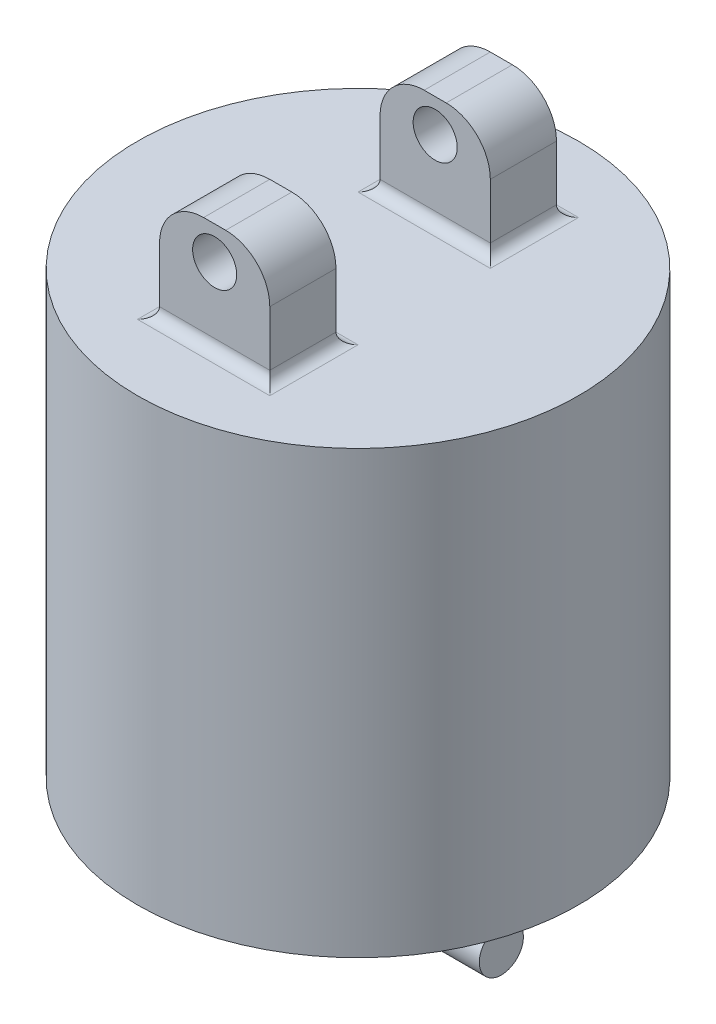
from build123d import *

# Parameters (mm, degrees)
SKETCH1_R                = 50
BOSS_EXTRUDE1_DEPTH      = 100
SKETCH6_W                = 25
SKETCH6_H                = 15
BOSS_EXTRUDE3_DEPTH      = 25
FILLET3_R                = 2.5
FILLET4_R                = 10
SKETCH7_R                = 5
CUT_EXTRUDE2_DEPTH       = 25
CIRPATTERN1_COUNT        = 2
FILLET3_OF_CIRPATTERN1_R = 2.5
FILLET4_OF_CIRPATTERN1_R = 10
SKETCH9_W                = 25
SKETCH9_H                = 25
BOSS_EXTRUDE4_DEPTH      = 15
BOSS_EXTRUDE4_DEPTH_BACK = 15
FILLET5_R                = 2.5
FILLET6_R                = 10
SKETCH10_R               = 5
BOSS_EXTRUDE5_DEPTH      = 32.5
BOSS_EXTRUDE5_DEPTH_BACK = 32.5


with BuildPart() as part:
    # Sketch1 → Boss-Extrude1 (new body)
    with BuildSketch(Plane(origin=(0, 0, 0), x_dir=(1, 0, 0), z_dir=(0, 1, 0))):
        Circle(SKETCH1_R)
    extrude(amount=BOSS_EXTRUDE1_DEPTH)

    # Sketch6 → Boss-Extrude3 (add)
    with BuildSketch(Plane(origin=(0, 100, 0), x_dir=(1, 0, 0), z_dir=(0, 1, 0))):
        with Locations((0, -25)):
            Rectangle(SKETCH6_W, SKETCH6_H)
    boss_extrude3 = extrude(amount=BOSS_EXTRUDE3_DEPTH)

    # Fillet3
    fillet3_edges = [part.edges().sort_by_distance(p)[0] for p in [
        (12.5, 100, 25),
        (0, 100, 17.5),
        (-12.5, 100, 25),
        (0, 100, 32.5),
    ]]
    fillet(fillet3_edges, radius=FILLET3_R)

    # Fillet4
    fillet4_edges = [part.edges().sort_by_distance(p)[0] for p in [
        (12.5, 125, 25),
        (-12.5, 125, 25),
    ]]
    fillet(fillet4_edges, radius=FILLET4_R)

    # Sketch7 → Cut-Extrude2 (cut)
    with BuildSketch(Plane.XY.offset(32.5)):
        with Locations((0, 117.5)):
            Circle(SKETCH7_R)
    cut_extrude2 = extrude(amount=-CUT_EXTRUDE2_DEPTH, mode=Mode.SUBTRACT)

    # CirPattern1: Boss-Extrude3, Cut-Extrude2 ×2 about axis
    cirpattern1_axis = Axis((0, 0, 0), (0, 1, 0))
    for i in range(1, CIRPATTERN1_COUNT):
        add(boss_extrude3.rotate(cirpattern1_axis, i * 360 / CIRPATTERN1_COUNT))
        add(cut_extrude2.rotate(cirpattern1_axis, i * 360 / CIRPATTERN1_COUNT), mode=Mode.SUBTRACT)

    # Fillet3 of CirPattern1
    fillet3_of_cirpattern1_edges = [part.edges().sort_by_distance(p)[0] for p in [
        (-12.5, 100, -25),
        (0, 100, -17.5),
        (12.5, 100, -25),
        (0, 100, -32.5),
    ]]
    fillet(fillet3_of_cirpattern1_edges, radius=FILLET3_OF_CIRPATTERN1_R)

    # Fillet4 of CirPattern1
    fillet4_of_cirpattern1_edges = [part.edges().sort_by_distance(p)[0] for p in [
        (-12.5, 125, -25),
        (12.5, 125, -25),
    ]]
    fillet(fillet4_of_cirpattern1_edges, radius=FILLET4_OF_CIRPATTERN1_R)

    # Sketch9 → Boss-Extrude4 (add, two sides)
    with BuildSketch(Plane(origin=(0, 0, 0), x_dir=(0, 0, -1), z_dir=(1, 0, 0))) as boss_extrude4_sk:
        with Locations((0, -12.5)):
            Rectangle(SKETCH9_W, SKETCH9_H)
    extrude(amount=BOSS_EXTRUDE4_DEPTH)
    extrude(boss_extrude4_sk.sketch, amount=-BOSS_EXTRUDE4_DEPTH_BACK)

    # Fillet5
    fillet5_edges = [part.edges().sort_by_distance(p)[0] for p in [
        (0, 0, 12.5),
        (-15, 0, 0),
        (0, 0, -12.5),
        (15, 0, 0),
    ]]
    fillet(fillet5_edges, radius=FILLET5_R)

    # Fillet6
    fillet6_edges = [part.edges().sort_by_distance(p)[0] for p in [
        (0, -25, 12.5),
        (0, -25, -12.5),
    ]]
    fillet(fillet6_edges, radius=FILLET6_R)

    # Sketch10 → Boss-Extrude5 (add, two sides)
    with BuildSketch(Plane(origin=(0, 0, 0), x_dir=(0, 0, -1), z_dir=(1, 0, 0))) as boss_extrude5_sk:
        with Locations((0, -17.5)):
            Circle(SKETCH10_R)
    extrude(amount=BOSS_EXTRUDE5_DEPTH)
    extrude(boss_extrude5_sk.sketch, amount=-BOSS_EXTRUDE5_DEPTH_BACK)


solid = part.part
